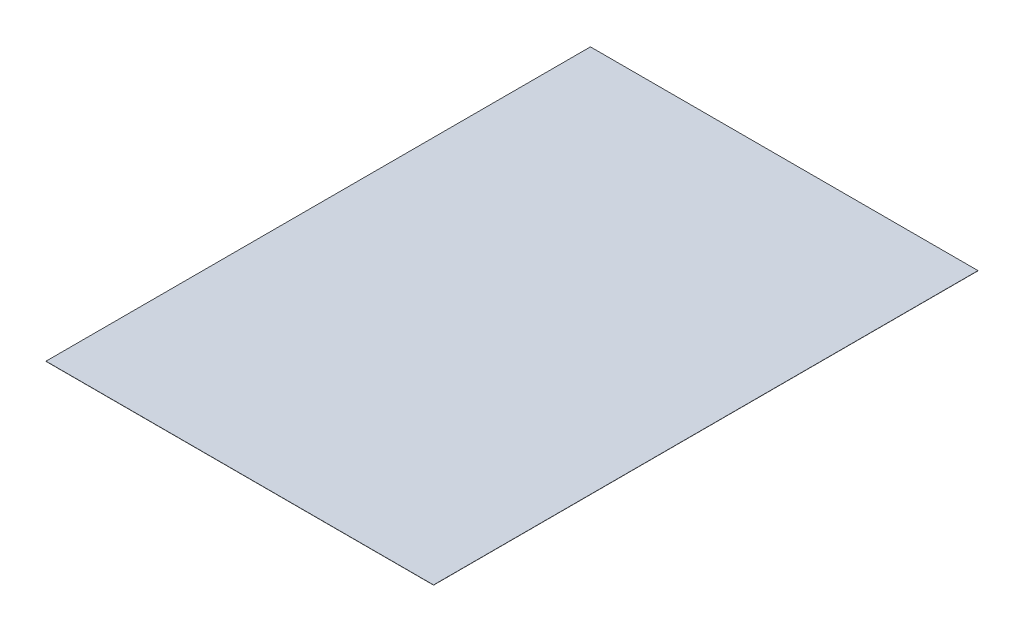
from build123d import *

# Parameters (mm, degrees)
SKETCH1_W           = 210
SKETCH1_H           = 295
BOSS_EXTRUDE1_DEPTH = 0.1


with BuildPart() as part:
    # Sketch1 → Boss-Extrude1 (new body)
    with BuildSketch(Plane(origin=(0, 0, 0), x_dir=(1, 0, 0), z_dir=(0, 1, 0))):
        with Locations((105, 147.5)):
            Rectangle(SKETCH1_W, SKETCH1_H)
    extrude(amount=BOSS_EXTRUDE1_DEPTH)


solid = part.part
